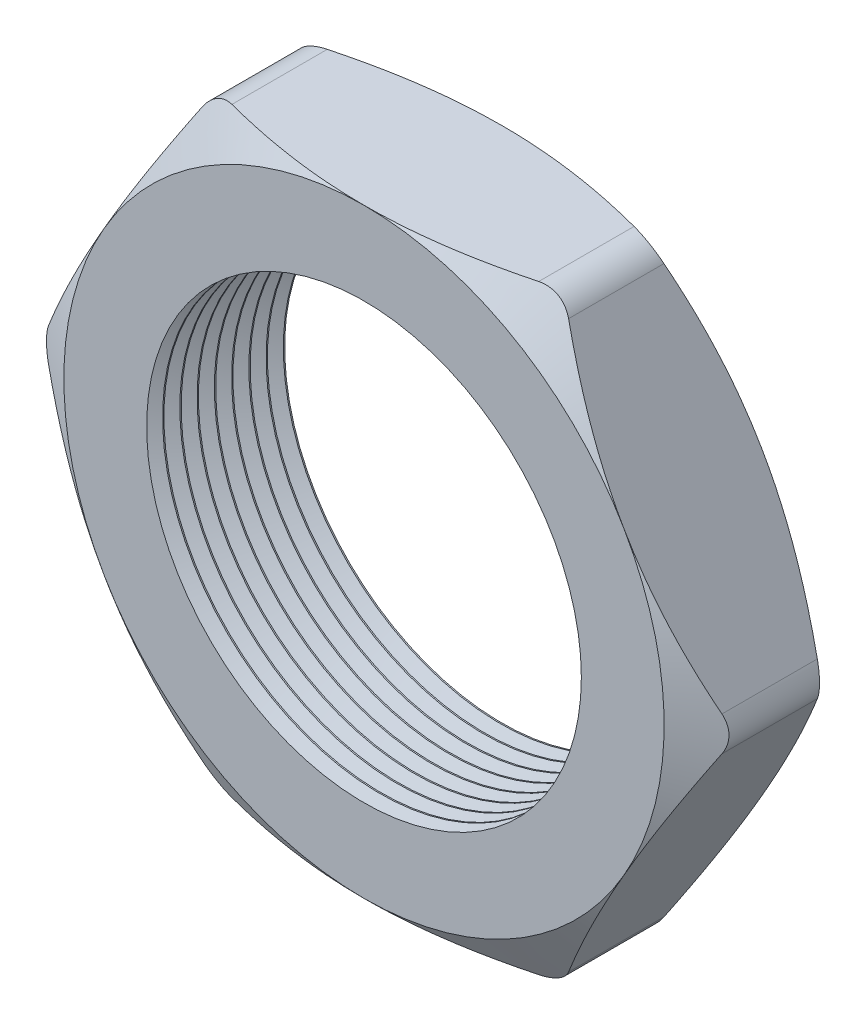
from build123d import *

# Parameters (mm, degrees)
SKETCH1_R          = 8.001
EXTRUDE1_DEPTH     = 5.08
SKETCH2_OUTSIDE_W  = 55.404
SKETCH2_OUTSIDE_H  = 51.986
SKETCH2_OUTSIDE_R  = 11.049
CUT_EXTRUDE1_DEPTH = 6.08
CUT_EXTRUDE1_DRAFT = -60
SKETCH3_OUTSIDE_W  = 55.404
SKETCH3_OUTSIDE_H  = 51.986
SKETCH3_OUTSIDE_R  = 11.049
CUT_EXTRUDE2_DEPTH = 6.08
CUT_EXTRUDE2_DRAFT = -60
FILLET1_R          = 1.27
LPATTERN1_COUNT    = 8
LPATTERN1_PITCH    = 0.635


with BuildPart() as part:
    # Sketch1 → Extrude1 (new body)
    with BuildSketch(Plane.XY):
        Polygon((-12.758286249, 0), (-6.379143124, -11.049), (6.379143124, -11.049), (12.758286249, 0), (6.379143124, 11.049), (-6.379143124, 11.049), align=None)
        Circle(SKETCH1_R, mode=Mode.SUBTRACT)
    extrude(amount=EXTRUDE1_DEPTH)


with BuildPart() as cut_extrude1_tool:
    # Sketch2 outside → Cut-Extrude1 (with draft: the straight prism first)
    with BuildSketch(Plane.XY.offset(5.08)):
        Rectangle(SKETCH2_OUTSIDE_W, SKETCH2_OUTSIDE_H)
        Circle(SKETCH2_OUTSIDE_R, mode=Mode.SUBTRACT)
    extrude(amount=-CUT_EXTRUDE1_DEPTH)
    # Cut-Extrude1: the draft: its side faces are tilted about the plane it starts from
    cut_extrude1_sides = [cut_extrude1_tool.faces().sort_by_distance(p)[0] for p in [
        (0, -25.993, 2.04),
        (27.702, 0, 2.04),
        (0, 25.993, 2.04),
        (-27.702, 0, 2.04),
        (-11.049, 0, 2.04),
    ]]
    draft(cut_extrude1_sides, Plane.XY.offset(5.08), CUT_EXTRUDE1_DRAFT)


with BuildPart() as part_1:
    add(part.part)

    # Cut-Extrude1: cut by cut_extrude1_tool
    add(cut_extrude1_tool.part, mode=Mode.SUBTRACT)


with BuildPart() as cut_extrude2_tool:
    # Sketch3 outside → Cut-Extrude2 (with draft: the straight prism first)
    with BuildSketch(Plane(origin=(0, 0, 0), x_dir=(-1, 0, 0), z_dir=(0, 0, -1))):
        Rectangle(SKETCH3_OUTSIDE_W, SKETCH3_OUTSIDE_H)
        Circle(SKETCH3_OUTSIDE_R, mode=Mode.SUBTRACT)
    extrude(amount=-CUT_EXTRUDE2_DEPTH)
    # Cut-Extrude2: the draft: its side faces are tilted about the plane it starts from
    cut_extrude2_sides = [cut_extrude2_tool.faces().sort_by_distance(p)[0] for p in [
        (0, -25.993, 3.04),
        (-27.702, 0, 3.04),
        (0, 25.993, 3.04),
        (27.702, 0, 3.04),
        (11.049, 0, 3.04),
    ]]
    draft(cut_extrude2_sides, Plane(origin=(0, 0, 0), x_dir=(-1, 0, 0), z_dir=(0, 0, -1)), CUT_EXTRUDE2_DRAFT)


with BuildPart() as part_2:
    add(part_1.part)

    # Cut-Extrude2: cut by cut_extrude2_tool
    add(cut_extrude2_tool.part, mode=Mode.SUBTRACT)

    # Fillet1
    fillet1_edges = [part_2.edges().sort_by_distance(p)[0] for p in [
        (12.758286249, 0, 2.54),
        (6.379143124, -11.049, 2.54),
        (-6.379143124, -11.049, 2.54),
        (-12.758286249, 0, 2.54),
        (-6.379143124, 11.049, 2.54),
        (6.379143124, 11.049, 2.54),
    ]]
    fillet(fillet1_edges, radius=FILLET1_R)

    # Sketch4 → Cut-Revolve1 (revolve, cut)
    with BuildSketch(Plane(origin=(0, 0, 0), x_dir=(1, 0, 0), z_dir=(0, 1, 0)), mode=Mode.PRIVATE) as cut_revolve1_sk:
        Polygon((-8.001, -5.08), (-8.001, -4.493412127), (-8.509, -4.786706063), align=None)
    cut_revolve1 = revolve(cut_revolve1_sk.sketch.rotate(Axis((0, 0, 0), (0, 0, 1)), 180), axis=Axis((0, 0, 0), (0, 0, 1)), mode=Mode.SUBTRACT)  # turned: the seam where the file's is

    # LPattern1: Cut-Revolve1 ×8
    with Locations(*[(0, 0, -i * LPATTERN1_PITCH) for i in range(1, LPATTERN1_COUNT)]):
        add(cut_revolve1, mode=Mode.SUBTRACT)


solid = part_2.part
